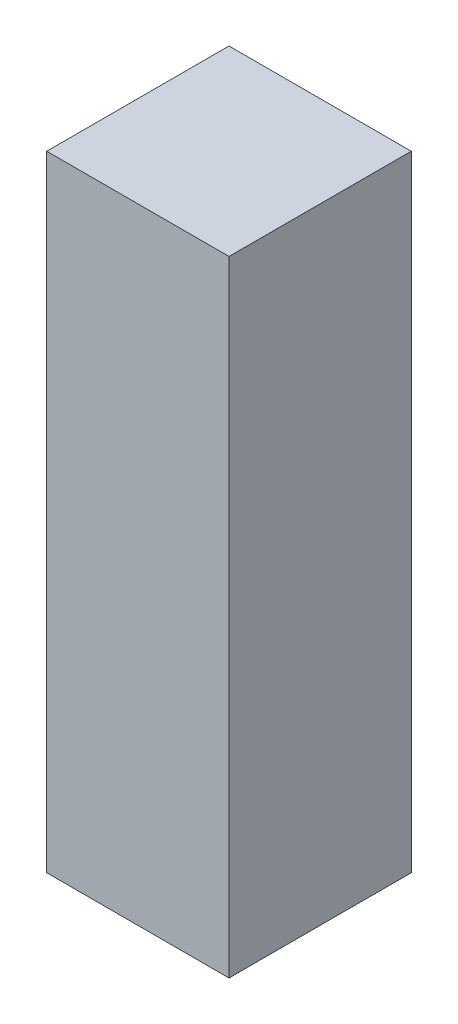
from build123d import *

# Parameters (mm, degrees)
SKETCH1_W           = 88.9
SKETCH1_H           = 88.9
BOSS_EXTRUDE1_DEPTH = 304.8


with BuildPart() as part:
    # Sketch1 → Boss-Extrude1 (new body)
    with BuildSketch(Plane(origin=(0, 0, 0), x_dir=(1, 0, 0), z_dir=(0, 1, 0))):
        Rectangle(SKETCH1_W, SKETCH1_H)
    extrude(amount=BOSS_EXTRUDE1_DEPTH)


solid = part.part
